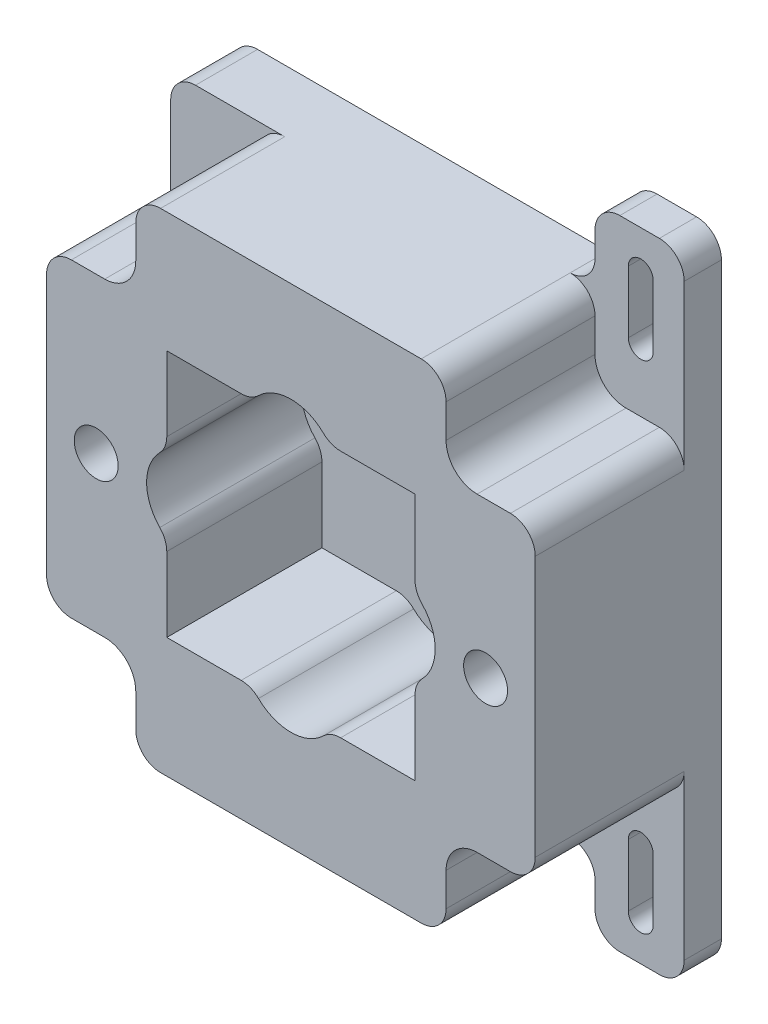
from build123d import *

# Parameters (mm, degrees)
SKETCH1_W              = 50
SKETCH1_H              = 50
BOSS_EXTRUDE1_DEPTH    = 6.35
SKETCH6_W              = 25.4
SKETCH6_H              = 25.4
BOSS_EXTRUDE3_DEPTH    = 12.7
SKETCH10_W             = 25.4
SKETCH10_H             = 25.4
CUT_EXTRUDE2_DEPTH     = 15.875
FILLET3_R              = 2.54
SKETCH11_W             = 9.125
SKETCH11_H             = 7.62
BOSS_EXTRUDE4_DEPTH    = 6.35
FILLET4_R              = 2.54
CUT_EXTRUDE3_DEPTH     = 7.35
FILLET4_OF_MIRROR1_R   = 2.54
FILLET5_R              = 2.54
CUT_EXTRUDE4_DEPTH     = 2.54
SKETCH14_R             = 4.7625
CUT_EXTRUDE5_DEPTH     = 16.875
FILLET6_R              = 2.54
F_10_CLEARANCE_HOLE1_D = 5.1054
F_8_CLEARANCE_HOLE1_D  = 4.4958


with BuildPart() as part:
    # Sketch1 → Boss-Extrude1 (new body)
    with BuildSketch(Plane.XY):
        Rectangle(SKETCH1_W, SKETCH1_H)
    extrude(amount=BOSS_EXTRUDE1_DEPTH)

    # Sketch6 → Boss-Extrude3 (add)
    with BuildSketch(Plane.XY.offset(6.35)):
        with BuildLine():
            Line((15.875, 19.05), (15.875, 25))
            Line((15.875, 25), (-15.875, 25))
            Line((-15.875, 25), (-15.875, 19.05))
            ThreePointArc((-15.875, 19.05), (-16.80493597, 16.80493597), (-19.05, 15.875))
            Line((-19.05, 15.875), (-25, 15.875))
            Line((-25, 15.875), (-25, -15.875))
            Line((-25, -15.875), (-19.05, -15.875))
            ThreePointArc((-19.05, -15.875), (-16.80493597, -16.80493597), (-15.875, -19.05))
            Line((-15.875, -19.05), (-15.875, -25))
            Line((-15.875, -25), (15.875, -25))
            Line((15.875, -25), (15.875, -19.05))
            ThreePointArc((15.875, -19.05), (16.80493597, -16.80493597), (19.05, -15.875))
            Line((19.05, -15.875), (25, -15.875))
            Line((25, -15.875), (25, 15.875))
            Line((25, 15.875), (19.05, 15.875))
            ThreePointArc((19.05, 15.875), (16.80493597, 16.80493597), (15.875, 19.05))
        make_face()
        Rectangle(SKETCH6_W, SKETCH6_H, mode=Mode.SUBTRACT)
    extrude(amount=BOSS_EXTRUDE3_DEPTH)

    # Sketch10 → Cut-Extrude2 (cut)
    with BuildSketch(Plane.XY.offset(19.05)):
        Rectangle(SKETCH10_W, SKETCH10_H)
    extrude(amount=-CUT_EXTRUDE2_DEPTH, mode=Mode.SUBTRACT)

    # Fillet3
    fillet3_edges = [part.edges().sort_by_distance(p)[0] for p in [
        (-15.875, -25, 12.7),
        (15.875, -25, 12.7),
        (25, -15.875, 12.7),
        (25, 15.875, 12.7),
        (15.875, 25, 12.7),
        (-15.875, 25, 12.7),
        (-25, 15.875, 12.7),
        (-25, -15.875, 12.7),
    ]]
    fillet(fillet3_edges, radius=FILLET3_R)

    # Sketch11 → Boss-Extrude4 (add)
    with BuildSketch(Plane.XY.offset(6.35)):
        with Locations((20.4375, -28.81)):
            Rectangle(SKETCH11_W, SKETCH11_H)
    boss_extrude4 = extrude(amount=-BOSS_EXTRUDE4_DEPTH)

    # Fillet4
    fillet4_edges = [part.edges().sort_by_distance(p)[0] for p in [
        (25, -32.62, 3.175),
        (15.875, -32.62, 3.175),
    ]]
    fillet(fillet4_edges, radius=FILLET4_R)

    # Sketch12 → Cut-Extrude3 (cut, through all)
    with BuildSketch(Plane.XY.offset(6.35)):
        with BuildLine():
            Line((19.285, -28.575), (19.285, -22.225))
            ThreePointArc((19.285, -22.225), (20.555, -20.955), (21.825, -22.225))
            Line((21.825, -22.225), (21.825, -28.575))
            ThreePointArc((21.825, -28.575), (20.555, -29.845), (19.285, -28.575))
        make_face()
    cut_extrude3 = extrude(amount=-CUT_EXTRUDE3_DEPTH, mode=Mode.SUBTRACT)

    # Mirror1: Boss-Extrude4, Cut-Extrude3 across plane
    add(boss_extrude4.mirror(Plane.ZX))
    add(cut_extrude3.mirror(Plane.ZX), mode=Mode.SUBTRACT)

    # Fillet4 of Mirror1
    fillet4_of_mirror1_edges = [part.edges().sort_by_distance(p)[0] for p in [
        (25, 32.62, 3.175),
        (15.875, 32.62, 3.175),
    ]]
    fillet(fillet4_of_mirror1_edges, radius=FILLET4_OF_MIRROR1_R)

    # Fillet5
    fillet5_edges = [part.edges().sort_by_distance(p)[0] for p in [
        (15.875, -25, 3.175),
        (15.875, 25, 3.175),
        (-25, 25, 3.175),
        (-25, -25, 3.175),
    ]]
    fillet(fillet5_edges, radius=FILLET5_R)

    # Sketch13 → Cut-Extrude4 (cut)
    with BuildSketch(Plane.XY.offset(6.35)):
        with BuildLine():
            Line((22.46, 32.62), (18.415, 32.62))
            ThreePointArc((18.415, 32.62), (16.618948776, 31.876051224), (15.875, 30.08))
            Line((15.875, 30.08), (15.875, 27.54))
            ThreePointArc((15.875, 27.54), (15.131051224, 25.743948776), (13.335, 25))
            ThreePointArc((13.335, 25), (15.131051224, 24.256051224), (15.875, 22.46))
            Line((15.875, 22.46), (15.875, 19.05))
            ThreePointArc((15.875, 19.05), (16.80493597, 16.80493597), (19.05, 15.875))
            Line((19.05, 15.875), (22.46, 15.875))
            ThreePointArc((22.46, 15.875), (24.256051224, 15.131051224), (25, 13.335))
            Line((25, 13.335), (25, 30.08))
            ThreePointArc((25, 30.08), (24.256051224, 31.876051224), (22.46, 32.62))
        make_face()
        with BuildLine():
            Line((15.875, -27.54), (15.875, -30.08))
            ThreePointArc((15.875, -30.08), (16.618948776, -31.876051224), (18.415, -32.62))
            Line((18.415, -32.62), (22.46, -32.62))
            ThreePointArc((22.46, -32.62), (24.256051224, -31.876051224), (25, -30.08))
            Line((25, -30.08), (25, -13.335))
            ThreePointArc((25, -13.335), (24.256051224, -15.131051224), (22.46, -15.875))
            Line((22.46, -15.875), (19.05, -15.875))
            ThreePointArc((19.05, -15.875), (16.80493597, -16.80493597), (15.875, -19.05))
            Line((15.875, -19.05), (15.875, -22.46))
            ThreePointArc((15.875, -22.46), (15.131051224, -24.256051224), (13.335, -25))
            ThreePointArc((13.335, -25), (15.131051224, -25.743948776), (15.875, -27.54))
        make_face()
    extrude(amount=-CUT_EXTRUDE4_DEPTH, mode=Mode.SUBTRACT)

    # Sketch14 → Cut-Extrude5 (cut, through all)
    with BuildSketch(Plane.XY.offset(3.175)):
        with Locations((-10, 0)):
            Circle(SKETCH14_R)
        with Locations((0, -10)):
            Circle(SKETCH14_R)
        with Locations((10, 0)):
            Circle(SKETCH14_R)
        with Locations((0, 10)):
            Circle(SKETCH14_R)
    extrude(amount=CUT_EXTRUDE5_DEPTH, mode=Mode.SUBTRACT)

    # Fillet6
    fillet6_edges = [part.edges().sort_by_distance(p)[0] for p in [
        (-12.7, 3.923188276, 11.1125),
        (-12.7, -3.923188276, 11.1125),
        (-3.923188276, -12.7, 11.1125),
        (3.923188276, -12.7, 11.1125),
        (12.7, 3.923188276, 11.1125),
        (12.7, -3.923188276, 11.1125),
        (-3.923188276, 12.7, 11.1125),
        (3.923188276, 12.7, 11.1125),
    ]]
    fillet(fillet6_edges, radius=FILLET6_R)

    # 10 Clearance Hole1 (through all)
    with Locations(Plane.XY.offset(3.175)):
        with Locations((-10, 0), (0, 10), (10, 0), (0, -10)):
            Hole(F_10_CLEARANCE_HOLE1_D / 2)

    # 8 Clearance Hole1 (through all)
    with Locations(Plane.XY.offset(19.05)):
        with Locations((-19.92, 0), (19.92, 0)):
            Hole(F_8_CLEARANCE_HOLE1_D / 2)


solid = part.part
